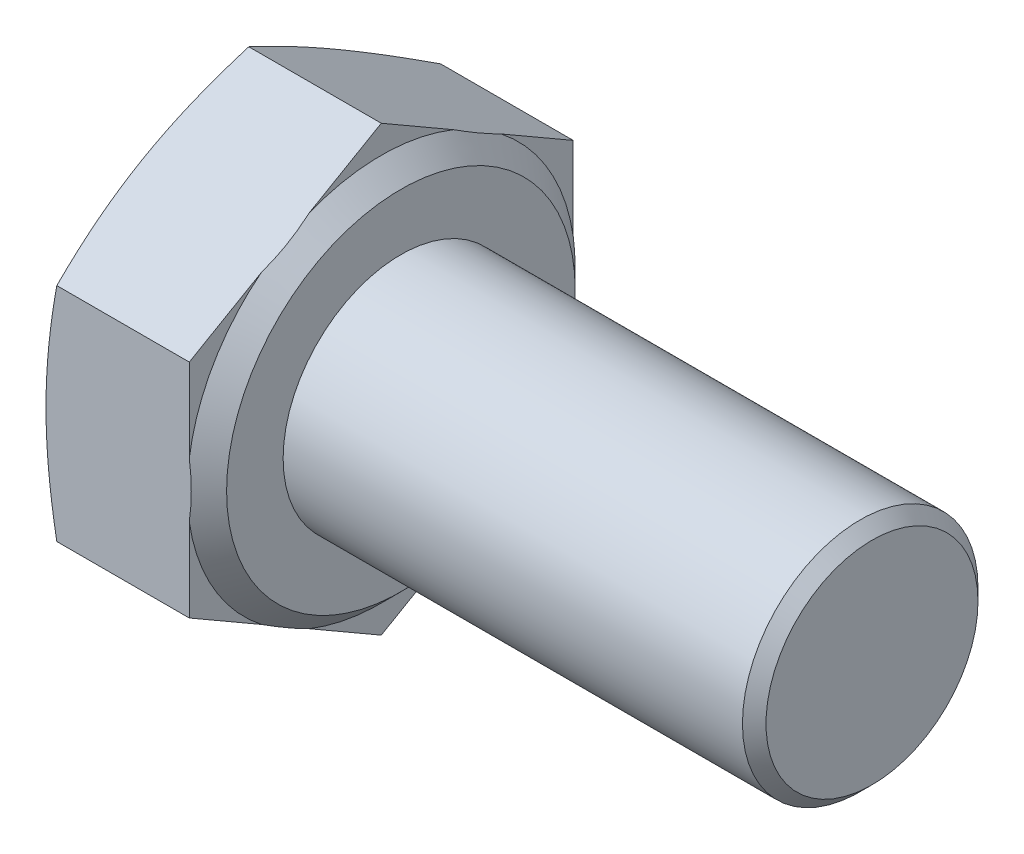
from build123d import *

# Parameters (mm, degrees)
BASEHEAD_DEPTH = 4.15
SKETCH5_R      = 3
BASEBODY_DEPTH = 12
CHAMFER1_SIZE  = 0.3


with BuildPart() as part:
    # Sketch2 → BaseHead (new body)
    with BuildSketch(Plane(origin=(0, 0, 0), x_dir=(0, 0, -1), z_dir=(1, 0, 0))):
        Polygon((4.89, -2.823242816), (4.89, 2.823242816), (0, 5.646485633), (-4.89, 2.823242816), (-4.89, -2.823242816), (0, -5.646485633), align=None)
    extrude(amount=BASEHEAD_DEPTH)

    # Sketch3 → BearingFace (revolve, cut)
    with BuildSketch(Plane.XY):
        Polygon((4.15, 5.646485633), (4.15, 4.44), (3.65, 4.94), (3.65, 5.646485633), align=None)
    revolve(axis=Axis((-0.957090588, 0, 0), (1, 0, 0)), mode=Mode.SUBTRACT)

    # Sketch4 → HeadChamfer (revolve, cut)
    with BuildSketch(Plane.XY):
        Polygon((0, 5.646485633), (0.275338253, 5.646485633), (0, 4.89), align=None)
    revolve(axis=Axis((-0.493528746, 0, 0), (1, 0, 0)), mode=Mode.SUBTRACT)

    # Sketch5 → BaseBody (add)
    with BuildSketch(Plane(origin=(4.15, 0, 0), x_dir=(0, 0, -1), z_dir=(1, 0, 0))):
        Circle(SKETCH5_R)
    extrude(amount=BASEBODY_DEPTH)

    # Chamfer1
    chamfer1_edges = [part.edges().sort_by_distance(p)[0] for p in [
        (16.15, 0, 3),
    ]]
    chamfer(chamfer1_edges, length=CHAMFER1_SIZE)


solid = part.part
